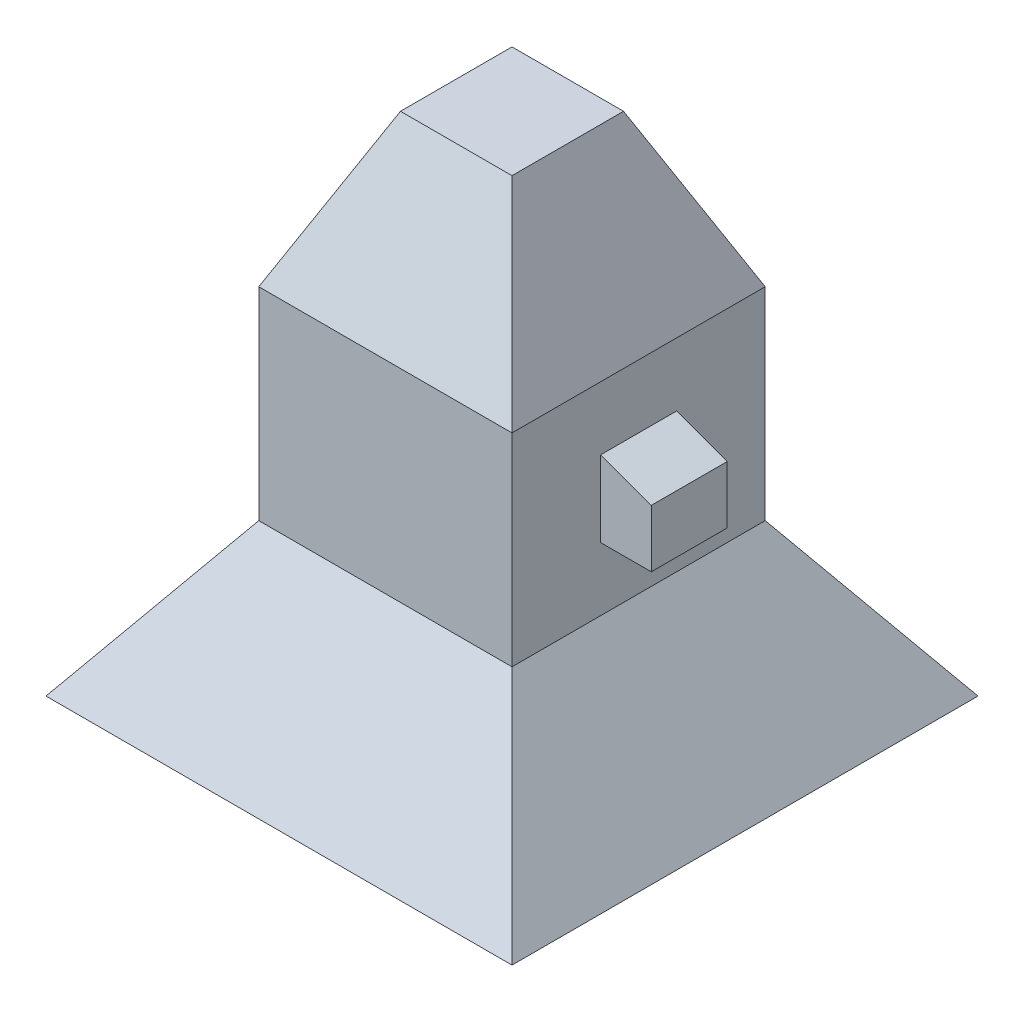
from build123d import *

# Parameters (mm, degrees)
SKETCH1_W           = 100
SKETCH1_H           = 100
BOSS_EXTRUDE1_DEPTH = 80
SKETCH2_W           = 100
SKETCH2_H           = 100
BOSS_EXTRUDE2_DEPTH = 60
BOSS_EXTRUDE2_TAPER = 25
SKETCH3_W           = 100
SKETCH3_H           = 100
BOSS_EXTRUDE3_DEPTH = 60
BOSS_EXTRUDE3_TAPER = -35
SKETCH5_W           = 144.024904586
SKETCH5_H           = 144.024904586
CUT_EXTRUDE2_DEPTH  = 20
CUT_EXTRUDE2_TAPER  = -35
SKETCH6_W           = 30
SKETCH6_H           = 30
BOSS_EXTRUDE4_DEPTH = 20
DRAFT5_ANGLE        = 20


with BuildPart() as part:
    # Sketch1 → Boss-Extrude1 (new body)
    with BuildSketch(Plane(origin=(0, 0, 0), x_dir=(1, 0, 0), z_dir=(0, 1, 0))):
        Rectangle(SKETCH1_W, SKETCH1_H)
    extrude(amount=BOSS_EXTRUDE1_DEPTH)

    # Sketch2 → Boss-Extrude2 (add)
    with BuildSketch(Plane(origin=(0, 80, 0), x_dir=(1, 0, 0), z_dir=(0, 1, 0))):
        Rectangle(SKETCH2_W, SKETCH2_H)
    extrude(amount=BOSS_EXTRUDE2_DEPTH, taper=BOSS_EXTRUDE2_TAPER)

    # Sketch3 → Boss-Extrude3 (add)
    with BuildSketch(Plane.XZ):
        Rectangle(SKETCH3_W, SKETCH3_H)
    extrude(amount=BOSS_EXTRUDE3_DEPTH, taper=BOSS_EXTRUDE3_TAPER)

    # Sketch5 → Cut-Extrude2 (cut)
    with BuildSketch(Plane(origin=(0, -40, 0), x_dir=(-1, 0, 0), z_dir=(0, -1, 0))):
        Rectangle(SKETCH5_W, SKETCH5_H)
    extrude(amount=CUT_EXTRUDE2_DEPTH, taper=CUT_EXTRUDE2_TAPER, mode=Mode.SUBTRACT)

    # Sketch6 → Boss-Extrude4 (add)
    with BuildSketch(Plane(origin=(50, 0, 0), x_dir=(0, 0, -1), z_dir=(1, 0, 0))):
        with Locations((0, 40)):
            Rectangle(SKETCH6_W, SKETCH6_H)
    extrude(amount=BOSS_EXTRUDE4_DEPTH)

    # Draft5
    draft5_faces = [part.faces().sort_by_distance(p)[0] for p in [
        (60, 55, 0),
    ]]
    draft(draft5_faces, Plane(origin=(50, 80, 50), x_dir=(0, 0, 1), z_dir=(1, 0, 0)), DRAFT5_ANGLE)


solid = part.part
